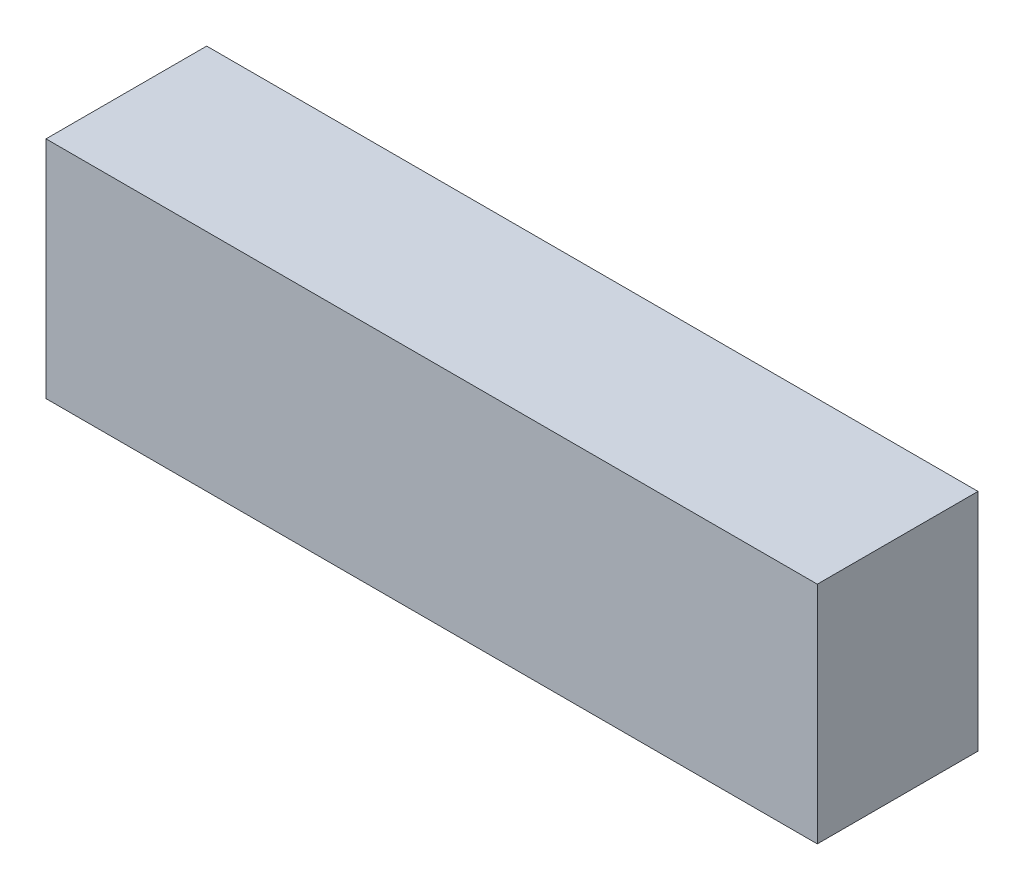
from build123d import *

# Parameters (mm, degrees)
SKETCH1_W           = 120
SKETCH1_H           = 35
BOSS_EXTRUDE1_DEPTH = 25


with BuildPart() as part:
    # Sketch1 → Boss-Extrude1 (new body)
    with BuildSketch(Plane.XY):
        with Locations((60, 17.5)):
            Rectangle(SKETCH1_W, SKETCH1_H)
    extrude(amount=BOSS_EXTRUDE1_DEPTH)


solid = part.part
